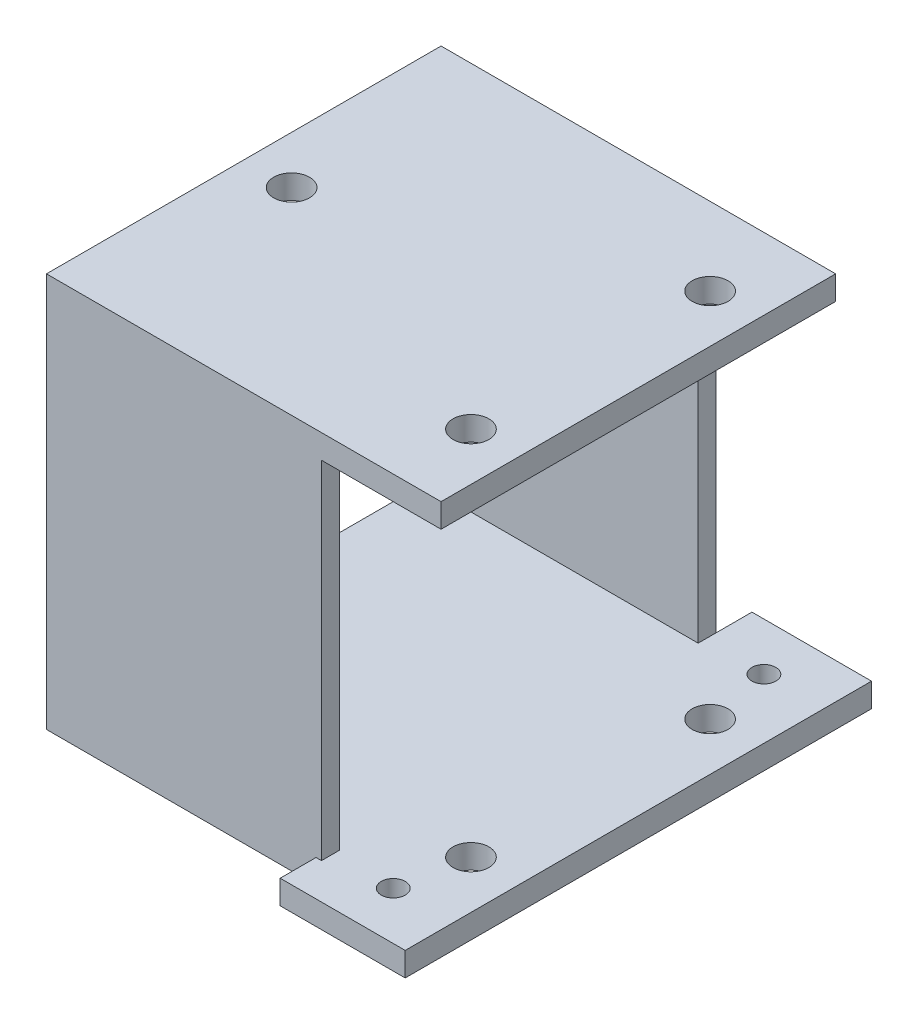
from build123d import *

# Parameters (mm, degrees)
SKETCH1_W           = 10.455425194
SKETCH1_H           = 3
SKETCH1_W_2         = 10
BOSS_EXTRUDE1_DEPTH = 2
SKETCH2_R           = 1
CUT_EXTRUDE2_DEPTH  = 47.542938032
BOSS_EXTRUDE3_DEPTH = 29
SKETCH3_W           = 33
SKETCH3_H           = 33
BOSS_EXTRUDE4_DEPTH = 2
SKETCH4_R           = 1.5
CUT_EXTRUDE4_DEPTH  = 58.019690289


with BuildPart() as part:
    # Sketch1 → Boss-Extrude1 (new body)
    with BuildSketch(Plane(origin=(0, 0, 0), x_dir=(1, 0, 0), z_dir=(0, 1, 0))):
        Polygon((-37.532221957, -24.451364186), (-14.987647151, -24.451364186), (-4.532221957, -24.451364186), (-4.532221957, 8.548635814), (-14.532221957, 8.548635814), (-37.532221957, 8.548635814), align=None)
        with Locations((-9.759934554, -25.951364186)):
            Rectangle(SKETCH1_W, SKETCH1_H)
        with Locations((-9.532221957, 10.048635814)):
            Rectangle(SKETCH1_W_2, SKETCH1_H)
    extrude(amount=BOSS_EXTRUDE1_DEPTH)

    # Sketch2 → Cut-Extrude2 (cut, through all)
    with BuildSketch(Plane(origin=(0, 2, 0), x_dir=(1, 0, 0), z_dir=(0, 1, 0))):
        with Locations(Location((-9.532221957, 7.548635814, 0), (0, 0, 270))):
            Circle(SKETCH2_R)
        with Locations(Location((-9.532221957, -23.451364186, 0), (0, 0, 270))):
            Circle(SKETCH2_R)
    extrude(amount=-CUT_EXTRUDE2_DEPTH, mode=Mode.SUBTRACT)

    # 3DSketch1 → Boss-Extrude3 (add)
    with BuildSketch(Plane(origin=(-37.532221957, 2, 22.951364186), x_dir=(0.589695128953028, 0, -0.8076259374791475), z_dir=(0, -1, 0))):
        Polygon((0, 0), (-1.211438906, 0.884542693), (12.35154906, 19.459939255), (13.562987966, 18.575396562), align=None)
        Polygon((39.003204997, 0), (37.79176609, 0.884542693), (24.228778124, -17.690853869), (25.440217031, -18.575396562), align=None)
    extrude(amount=-BOSS_EXTRUDE3_DEPTH)

    # Sketch3 → Boss-Extrude4 (add)
    with BuildSketch(Plane(origin=(0, 31, 0), x_dir=(1, 0, 0), z_dir=(0, 1, 0))):
        with Locations((-21.032221957, -7.951364186)):
            Rectangle(SKETCH3_W, SKETCH3_H)
    extrude(amount=BOSS_EXTRUDE4_DEPTH)

    # Sketch4 → Cut-Extrude4 (cut, through all)
    with BuildSketch(Plane(origin=(0, 33, 0), x_dir=(1, 0, 0), z_dir=(0, 1, 0))):
        with Locations(Location((-8.532221957, -17.951364186, 0), (0, 0, 270))):
            Circle(SKETCH4_R)
        with Locations(Location((-8.532221957, 2.048635814, 0), (0, 0, 270))):
            Circle(SKETCH4_R)
        with Locations(Location((-33.532221957, -7.951364186, 0), (0, 0, 270))):
            Circle(SKETCH4_R)
    extrude(amount=-CUT_EXTRUDE4_DEPTH, mode=Mode.SUBTRACT)


solid = part.part
